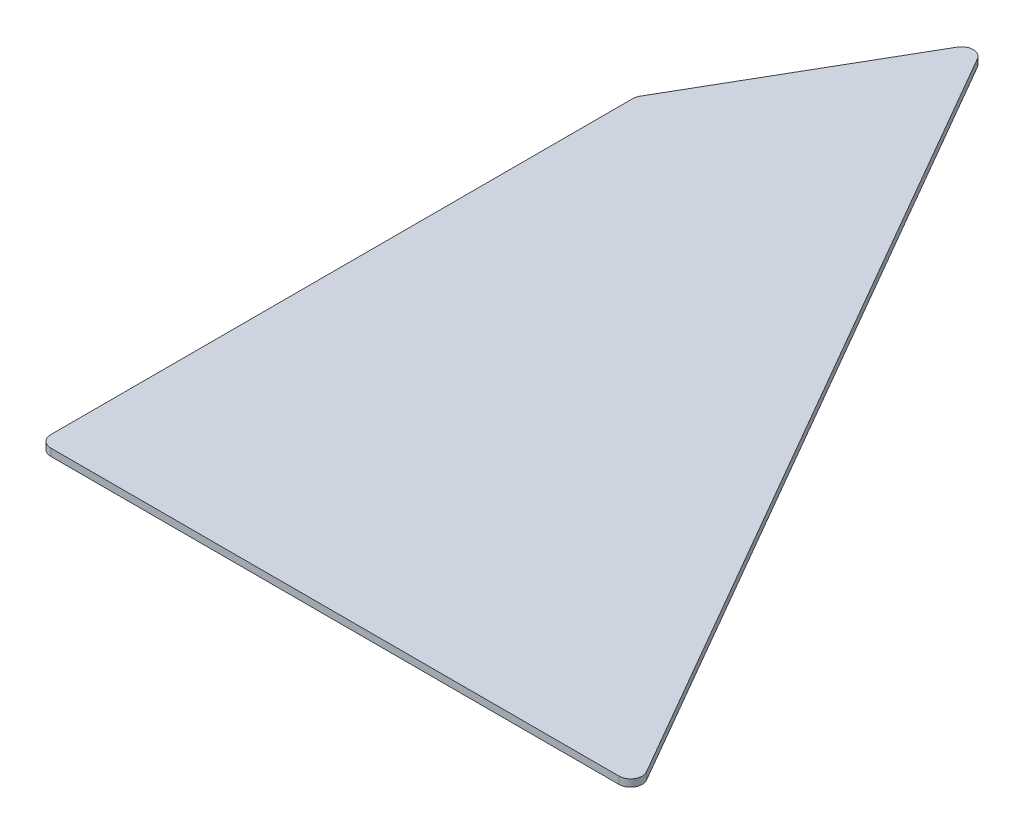
from build123d import *

# Parameters (mm, degrees)
BOSS_EXTRUDE1_DEPTH = 6.35
CUT_EXTRUDE2_DEPTH  = 3.175
FILLET1_R           = 5.08


with BuildPart() as part:
    # Sketch1 → Boss-Extrude1 (new body)
    with BuildSketch(Plane(origin=(0, 0, 0), x_dir=(1, 0, 0), z_dir=(0, 1, 0))):
        Polygon((172.72, 12.7), (435.202954744, 12.7), (228.6, 370.54681461), (172.72, 273.759815483), align=None)
    extrude(amount=BOSS_EXTRUDE1_DEPTH)

    # Sketch1_3 → Cut-Extrude2 (cut)
    with BuildSketch(Plane(origin=(0, 0, 0), x_dir=(1, 0, 0), z_dir=(0, 1, 0))):
        Polygon((172.72, 12.7), (435.202954744, 12.7), (228.6, 370.54681461), (172.72, 273.759815483), align=None)
        Polygon((413.205909488, 25.4), (185.42, 25.4), (185.42, 270.356860739), (228.6, 345.14681461), align=None, mode=Mode.SUBTRACT)
    extrude(amount=CUT_EXTRUDE2_DEPTH, mode=Mode.SUBTRACT)

    # Fillet1
    fillet1_edges = [part.edges().sort_by_distance(p)[0] for p in [
        (228.6, 4.7625, -370.54681461),
        (172.72, 4.7625, -273.759815483),
        (172.72, 4.7625, -12.7),
        (435.202954744, 4.7625, -12.7),
    ]]
    fillet(fillet1_edges, radius=FILLET1_R)


solid = part.part
